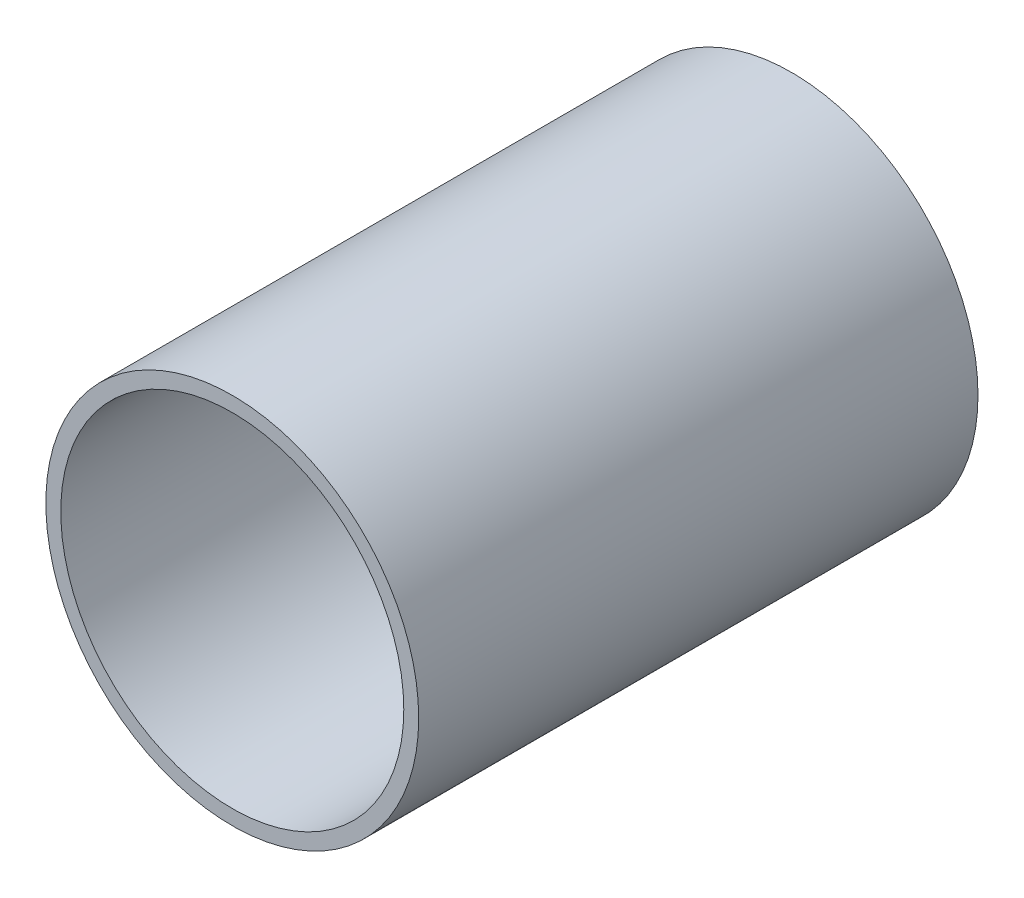
from build123d import *

# Parameters (mm, degrees)
SKETCH1_R               = 10
BOSS_EXTRUDE1_DEPTH     = 30
SKETCH2_R               = 2.5
BOSS_EXTRUDE3_DEPTH     = 2
SHELL1_T                = -0.8
SKETCH3_R               = 0.5
CUT_EXTRUDE2_DEPTH      = 34.166247904
CUT_EXTRUDE2_DEPTH_BACK = 34.166247904


with BuildPart() as part:
    # Sketch1 → Boss-Extrude1 (new body)
    with BuildSketch(Plane.XY):
        Circle(SKETCH1_R)
    extrude(amount=BOSS_EXTRUDE1_DEPTH)

    # Sketch2 → Boss-Extrude3 (add)
    with BuildSketch(Plane.XY):
        Circle(SKETCH2_R)
    extrude(amount=-BOSS_EXTRUDE3_DEPTH)

    # Shell1
    shell1_openings = [part.faces().sort_by_distance(p)[0] for p in [
        (0, 0, 30),
        (0, 0, -2),
    ]]
    offset(amount=SHELL1_T, openings=shell1_openings, kind=Kind.INTERSECTION)

    # Sketch3 → Cut-Extrude2 (cut, two sides)
    with BuildSketch(Plane.XY) as cut_extrude2_sk:
        with Locations((5, 0)):
            Circle(SKETCH3_R)
        with Locations((0, -5)):
            Circle(SKETCH3_R)
        with Locations((-5, 0)):
            Circle(SKETCH3_R)
        with Locations((0, 5)):
            Circle(SKETCH3_R)
    extrude(amount=CUT_EXTRUDE2_DEPTH, mode=Mode.SUBTRACT)
    extrude(cut_extrude2_sk.sketch, amount=-CUT_EXTRUDE2_DEPTH_BACK, mode=Mode.SUBTRACT)


solid = part.part
